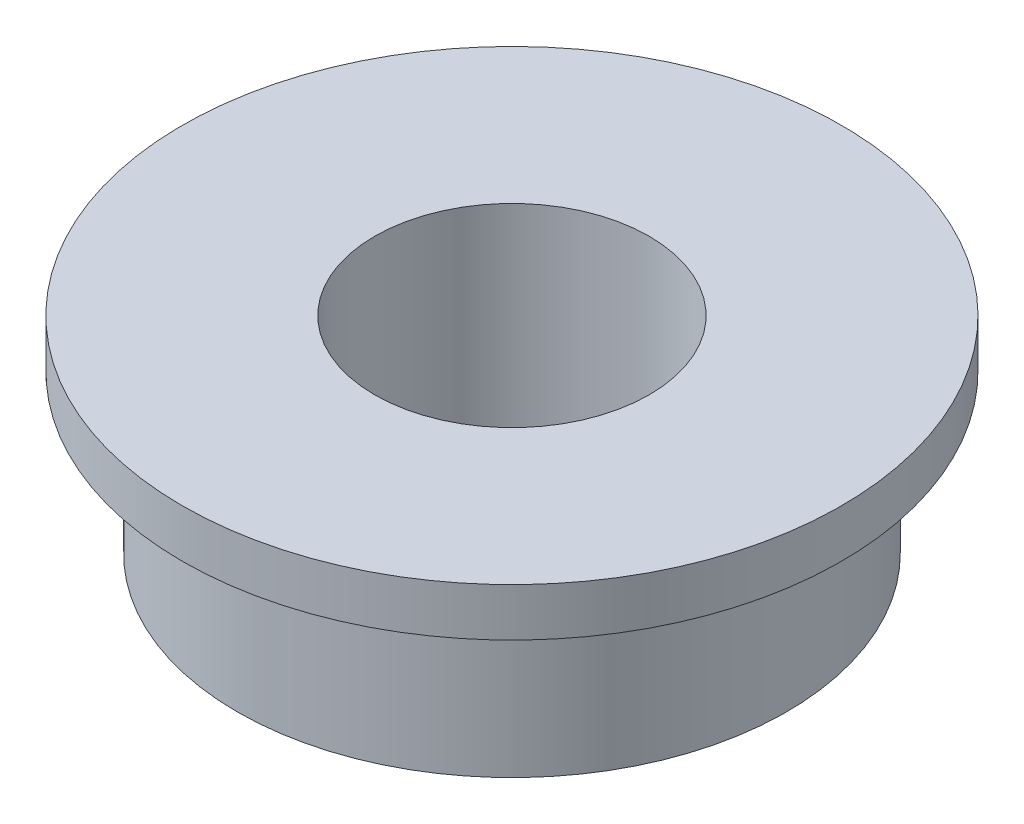
from build123d import *

# Parameters (mm, degrees)
SKETCH1_R           = 4
SKETCH1_R_2         = 2
BOSS_EXTRUDE1_DEPTH = 3
SKETCH2_R           = 4.8
SKETCH2_R_2         = 2.5
BOSS_EXTRUDE2_DEPTH = 0.7


with BuildPart() as part:
    # Sketch1 → Boss-Extrude1 (new body)
    with BuildSketch(Plane(origin=(0, 0, 0), x_dir=(1, 0, 0), z_dir=(0, 1, 0))):
        Circle(SKETCH1_R)
        Circle(SKETCH1_R_2, mode=Mode.SUBTRACT)
    extrude(amount=BOSS_EXTRUDE1_DEPTH)

    # Sketch2 → Boss-Extrude2 (add)
    with BuildSketch(Plane(origin=(0, 3, 0), x_dir=(-1, 0, 0), z_dir=(0, 1, 0))):
        Circle(SKETCH2_R)
        Circle(SKETCH2_R_2, mode=Mode.SUBTRACT)
    extrude(amount=-BOSS_EXTRUDE2_DEPTH)


solid = part.part
